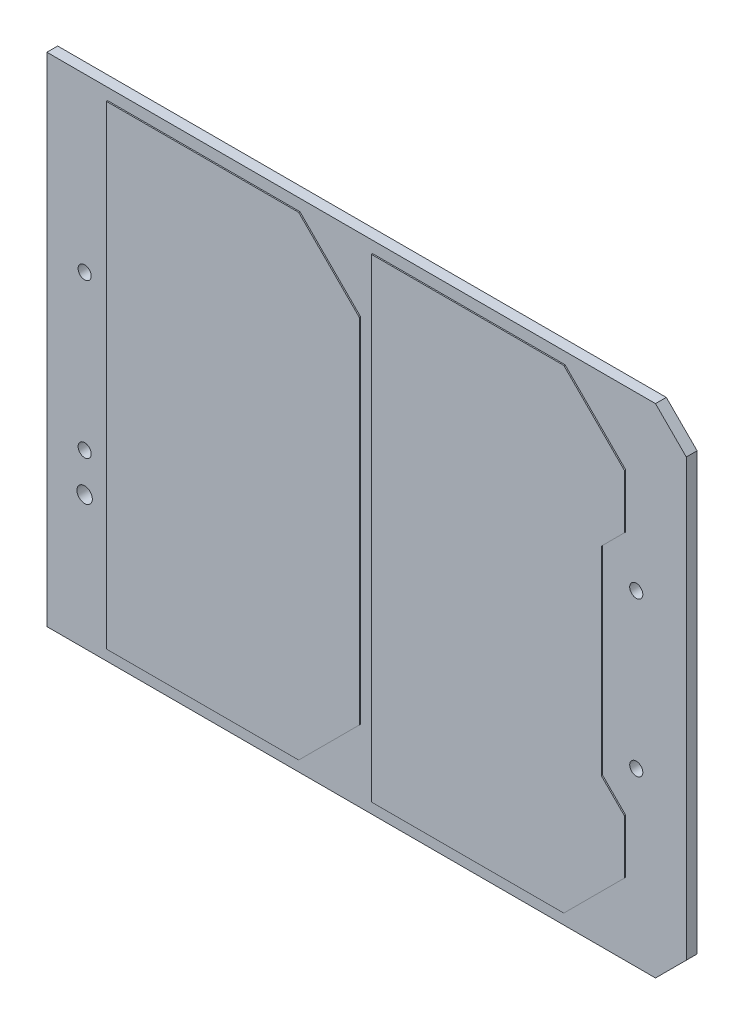
from build123d import *

# Parameters (mm, degrees)
SKETCH1_W           = 105.41
SKETCH1_H           = 82
SKETCH1_R           = 1.0795
SKETCH1_R_2         = 1.27
BOSS_EXTRUDE1_DEPTH = 1.778
BOSS_EXTRUDE2_DEPTH = 0.2
CHAMFER2_SIZE       = 5.08


with BuildPart() as part:
    # Sketch1 → Boss-Extrude1 (new body)
    with BuildSketch(Plane.XY):
        Rectangle(SKETCH1_W, SKETCH1_H)
        with Locations((44.45, 12.7)):
            Circle(SKETCH1_R, mode=Mode.SUBTRACT)
        with Locations((44.45, -12.7)):
            Circle(SKETCH1_R, mode=Mode.SUBTRACT)
        with Locations((-46.482, 12.7)):
            Circle(SKETCH1_R, mode=Mode.SUBTRACT)
        with Locations((-46.482, -12.7)):
            Circle(SKETCH1_R, mode=Mode.SUBTRACT)
        with Locations((-46.482, -19.05)):
            Circle(SKETCH1_R_2, mode=Mode.SUBTRACT)
    extrude(amount=BOSS_EXTRUDE1_DEPTH)

    # Sketch2 → Boss-Extrude2 (add)
    with BuildSketch(Plane.XY.offset(1.778)):
        Polygon((-11, 39.095), (-1, 29.095), (-1, -29.095), (-11, -39.095), (-42.705, -39.095), (-42.705, 39.095), align=None)
        Polygon((42.705, 20.205), (38.895, 16.395), (38.895, -16.395), (42.705, -20.205), (42.705, -29.095), (32.705, -39.095), (1, -39.095), (1, 39.095), (32.705, 39.095), (42.705, 29.095), align=None)
    extrude(amount=BOSS_EXTRUDE2_DEPTH)

    # Chamfer2
    chamfer2_edges = [part.edges().sort_by_distance(p)[0] for p in [
        (52.705, 41, 0.889),
        (52.705, -41, 0.889),
    ]]
    chamfer(chamfer2_edges, length=CHAMFER2_SIZE)


solid = part.part
